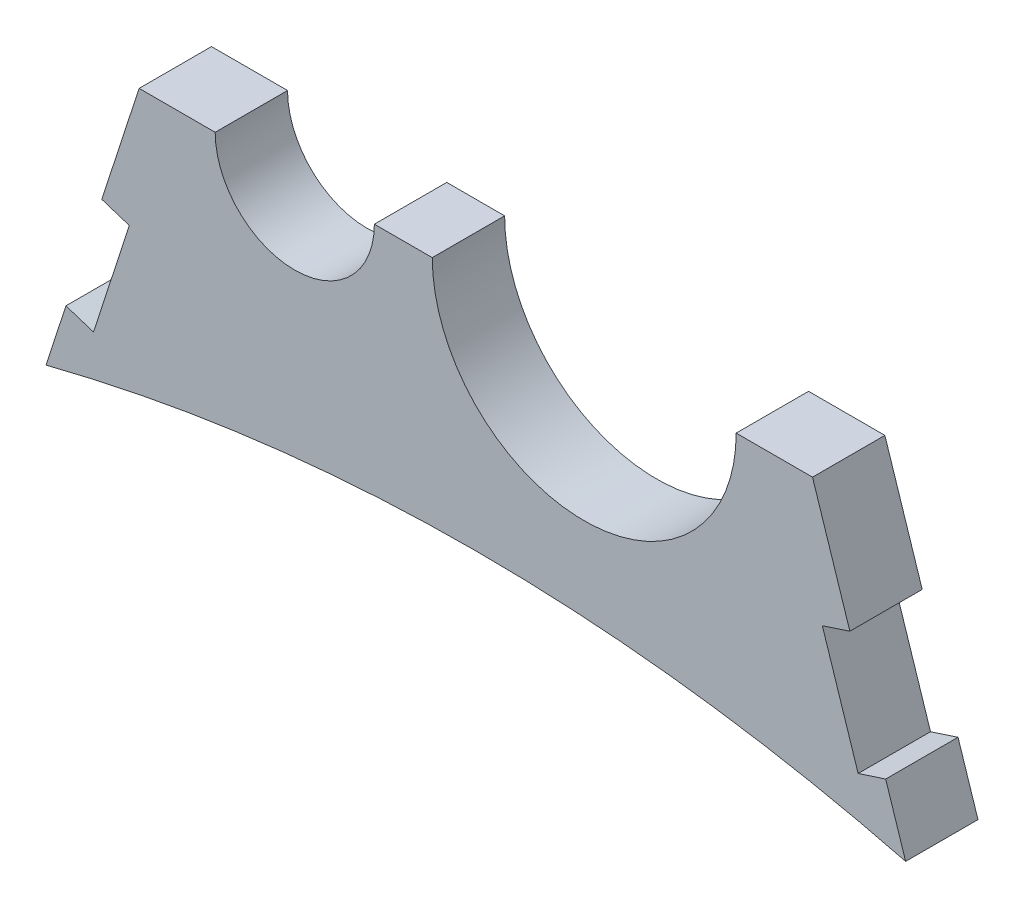
from build123d import *

# Parameters (mm, degrees)
BOSS_EXTRUDE2_DEPTH = 6.35


with BuildPart() as part:
    # Sketch1 → Boss-Extrude2 (new body)
    with BuildSketch(Plane.XY):
        with BuildLine():
            Line((37.717239544, 147.658964649), (35.965487423, 153.043027332))
            Line((35.965487423, 153.043027332), (33.550115758, 152.257164929))
            Line((33.550115758, 152.257164929), (30.406666146, 161.918651592))
            Line((30.406666146, 161.918651592), (32.822037812, 162.704513995))
            Line((32.822037812, 162.704513995), (29.545241798, 172.775844825))
            Line((29.545241798, 172.775844825), (22.8473, 172.775844825))
            ThreePointArc((22.8473, 172.775844825), (9.5123, 159.440844825), (-3.8227, 172.775844825))
            Line((-3.8227, 172.775844825), (-8.9027, 172.775844825))
            ThreePointArc((-8.9027, 172.775844825), (-15.8877, 165.790844825), (-22.8727, 172.775844825))
            Line((-22.8727, 172.775844825), (-29.545241798, 172.775844825))
            Line((-29.545241798, 172.775844825), (-32.822037812, 162.704513995))
            Line((-32.822037812, 162.704513995), (-30.406666146, 161.918651592))
            Line((-30.406666146, 161.918651592), (-33.550115758, 152.257164929))
            Line((-33.550115758, 152.257164929), (-35.965487423, 153.043027332))
            Line((-35.965487423, 153.043027332), (-37.717239544, 147.658964649))
            ThreePointArc((-37.717239544, 147.658964649), (0, 152.4), (37.717239544, 147.658964649))
        make_face()
    extrude(amount=BOSS_EXTRUDE2_DEPTH)


solid = part.part
